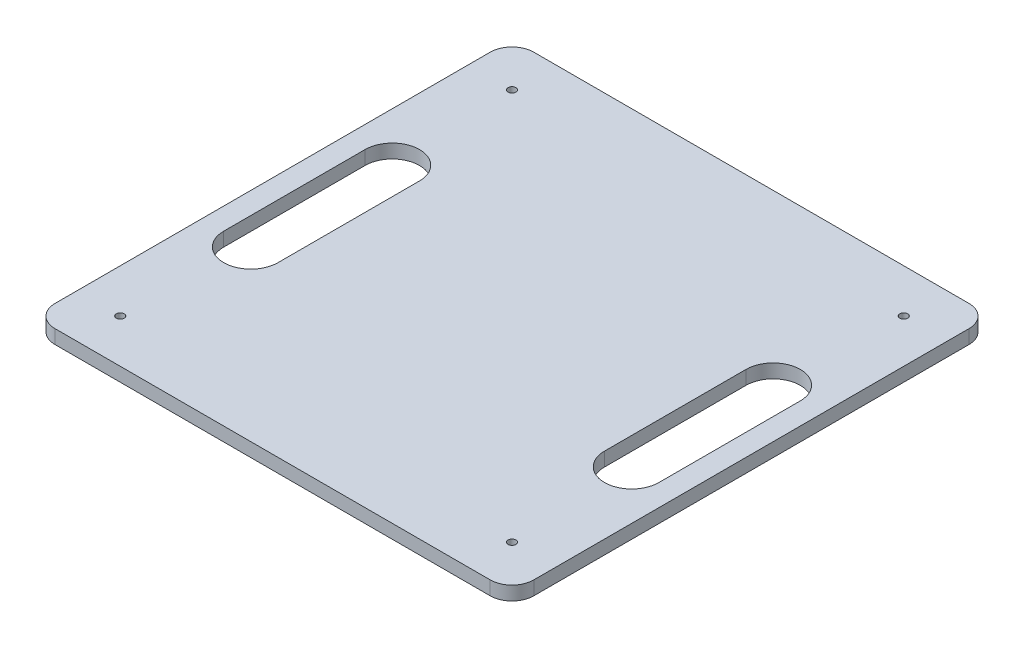
from build123d import *

# Parameters (mm, degrees)
SKETCH2_W           = 220
SKETCH2_H           = 220
BOSS_EXTRUDE1_DEPTH = 6.35
SKETCH3_R           = 1.8
CUT_EXTRUDE1_DEPTH  = 6.35
FILLET1_R           = 10
CUT_EXTRUDE2_DEPTH  = 10


with BuildPart() as part:
    # Sketch2 → Boss-Extrude1 (new body)
    with BuildSketch(Plane(origin=(0, 0, 0), x_dir=(1, 0, 0), z_dir=(0, 1, 0))):
        Rectangle(SKETCH2_W, SKETCH2_H)
    extrude(amount=BOSS_EXTRUDE1_DEPTH)

    # Sketch3 → Cut-Extrude1 (cut)
    with BuildSketch(Plane(origin=(0, 0, 0), x_dir=(-1, 0, 0), z_dir=(0, -1, 0))):
        with Locations((90, -90)):
            Circle(SKETCH3_R)
        with Locations((90, 90)):
            Circle(SKETCH3_R)
        with Locations((-90, 90)):
            Circle(SKETCH3_R)
        with Locations((-90, -90)):
            Circle(SKETCH3_R)
    extrude(amount=-CUT_EXTRUDE1_DEPTH, mode=Mode.SUBTRACT)

    # Fillet1
    fillet1_edges = [part.edges().sort_by_distance(p)[0] for p in [
        (110, 3.175, 110),
        (-110, 3.175, 110),
        (-110, 3.175, -110),
        (110, 3.175, -110),
    ]]
    fillet(fillet1_edges, radius=FILLET1_R)

    # Sketch7 → Cut-Extrude2 (cut)
    with BuildSketch(Plane(origin=(0, 6.35, 0), x_dir=(1, 0, 0), z_dir=(0, 1, 0))):
        with BuildLine():
            Line((-100, 32.5), (-100, -32.5))
            ThreePointArc((-100, -32.5), (-87.5, -45), (-75, -32.5))
            Line((-75, -32.5), (-75, 32.5))
            ThreePointArc((-75, 32.5), (-87.5, 45), (-100, 32.5))
        make_face()
        with BuildLine():
            Line((75, 32.5), (75, -32.5))
            ThreePointArc((75, -32.5), (87.5, -45), (100, -32.5))
            Line((100, -32.5), (100, 32.5))
            ThreePointArc((100, 32.5), (87.5, 45), (75, 32.5))
        make_face()
    extrude(amount=-CUT_EXTRUDE2_DEPTH, mode=Mode.SUBTRACT)


solid = part.part
